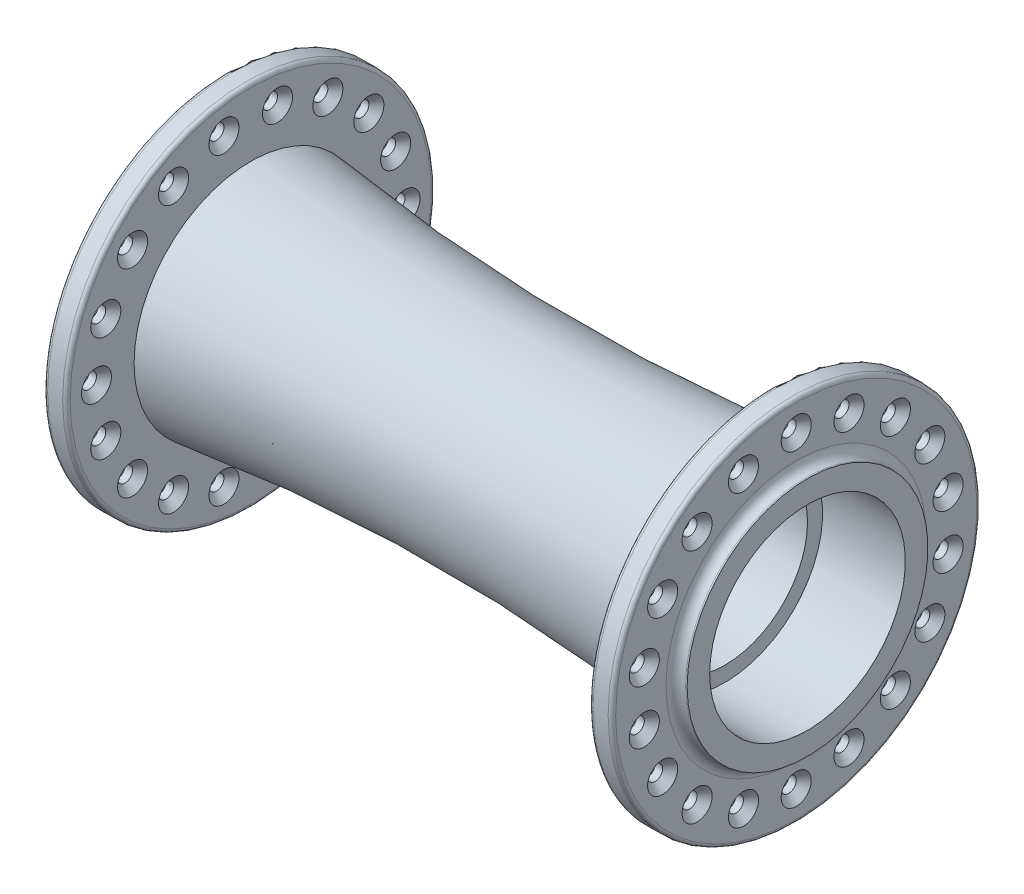
from build123d import *

# Parameters (mm, degrees)
CONG_1_R                                  = 0.5
ESQUISSE2_R                               = 1
ENL_V_MAT_EXTRU_1_DEPTH                   = 3
ESQUISSE3_R                               = 1
ENL_V_MAT_EXTRU_2_DEPTH                   = 3
CHANFREIN1_SIZE                           = 1
R_P_TITION_CIRCULAIRE1_COUNT              = 18
CHANFREIN1_OF_R_P_TITION_CIRCULAIRE1_SIZE = 1
ESQUISSE4_W                               = 11
ESQUISSE4_H                               = 13


with BuildPart() as part:
    # Esquisse1 → Révolution1 (revolve)
    with BuildSketch(Plane.XY, mode=Mode.PRIVATE) as r_volution1_sk:
        with BuildLine():
            Line((-39.25, 11), (39.25, 11))
            Line((39.25, 11), (39.25, 16))
            Line((39.25, 16), (39.05, 16))
            ThreePointArc((39.05, 16), (38.130761184, 16.380761184), (37.75, 17.3))
            Line((37.75, 17.3), (37.75, 24.5))
            Line((37.75, 24.5), (34.75, 24.5))
            Line((34.75, 24.5), (34.75, 15.5))
            ThreePointArc((34.75, 15.5), (0, 13.254435071), (-34.75, 15.5))
            Line((-34.75, 15.5), (-34.75, 24.5))
            Line((-34.75, 24.5), (-37.75, 24.5))
            Line((-37.75, 24.5), (-37.75, 17.3))
            ThreePointArc((-37.75, 17.3), (-38.130761184, 16.380761184), (-39.05, 16))
            Line((-39.05, 16), (-39.25, 16))
            Line((-39.25, 16), (-39.25, 11))
        make_face()
    revolve(r_volution1_sk.sketch.rotate(Axis((-56.164462081, 0, 0), (1, 0, 0)), 90), axis=Axis((-56.164462081, 0, 0), (1, 0, 0)))  # turned: the seam where the file's is

    # Congé1
    cong_1_edges = [part.edges().sort_by_distance(p)[0] for p in [
        (34.75, 0, -24.5),
        (37.75, 0, -24.5),
        (-37.75, 0, -24.5),
        (-34.75, 0, -24.5),
    ]]
    fillet(cong_1_edges, radius=CONG_1_R)

    # Esquisse2 → Enlèv. mat.-Extru.1 (cut)
    with BuildSketch(Plane(origin=(37.75, 0, 0), x_dir=(0, 0, -1), z_dir=(1, 0, 0))):
        with Locations((0, 20.5)):
            Circle(ESQUISSE2_R)
    enl_v_mat_extru_1 = extrude(amount=-ENL_V_MAT_EXTRU_1_DEPTH, mode=Mode.SUBTRACT)

    # Esquisse3 → Enlèv. mat.-Extru.2 (cut)
    with BuildSketch(Plane.ZY.offset(37.75)):
        with Locations((-3.559787642, 20.188558937)):
            Circle(ESQUISSE3_R)
    enl_v_mat_extru_2 = extrude(amount=-ENL_V_MAT_EXTRU_2_DEPTH, mode=Mode.SUBTRACT)

    # Chanfrein1
    chanfrein1_edges = [part.edges().sort_by_distance(p)[0] for p in [
        (37.75, 20.5, 1),
        (34.75, 20.5, 1),
        (-34.75, 20.188558937, -4.559787642),
        (-37.75, 20.188558937, -4.559787642),
    ]]
    chamfer(chanfrein1_edges, length=CHANFREIN1_SIZE)

    # Répétition circulaire1: Enlèv. mat.-Extru.1, Enlèv. mat.-Extru.2 ×18 about axis
    r_p_tition_circulaire1_axis = Axis((0, 0, 0), (1, 0, 0))
    add([enl_v_mat_extru_1.rotate(r_p_tition_circulaire1_axis, i * 360 / R_P_TITION_CIRCULAIRE1_COUNT) for i in range(1, R_P_TITION_CIRCULAIRE1_COUNT)], mode=Mode.SUBTRACT)
    add([enl_v_mat_extru_2.rotate(r_p_tition_circulaire1_axis, i * 360 / R_P_TITION_CIRCULAIRE1_COUNT) for i in range(1, R_P_TITION_CIRCULAIRE1_COUNT)], mode=Mode.SUBTRACT)

    # Chanfrein1 of Répétition circulaire1
    chanfrein1_of_r_p_tition_circulaire1_edges = [part.edges().sort_by_distance(p)[0] for p in [
        (37.75, 18.921678583, 7.951105559),
        (34.75, 18.921678583, 7.951105559),
        (-34.75, 20.53057908, 2.620095021),
        (-37.75, 20.53057908, 2.620095021),
        (37.75, 15.061123474, 13.943190442),
        (34.75, 15.061123474, 13.943190442),
        (-34.75, 18.396308387, 9.483955557),
        (-37.75, 18.396308387, 9.483955557),
        (37.75, 9.383974596, 18.253520778),
        (34.75, 9.383974596, 18.253520778),
        (-34.75, 14.043171402, 15.203911084),
        (-37.75, 14.043171402, 15.203911084),
        (37.75, 2.574979889, 20.362207114),
        (34.75, 2.574979889, 20.362207114),
        (-34.75, 7.996220691, 19.090050548),
        (-37.75, 7.996220691, 19.090050548),
        (37.75, -4.544595395, 20.014910759),
        (34.75, -4.544595395, 20.014910759),
        (-34.75, 0.984807753, 20.673648178),
        (-37.75, 0.984807753, 20.673648178),
        (37.75, -11.116025404, 17.253520778),
        (34.75, -11.116025404, 17.253520778),
        (-34.75, -6.145387534, 19.763698726),
        (-37.75, -6.145387534, 19.763698726),
        (37.75, -16.346698694, 12.411101555),
        (34.75, -16.346698694, 12.411101555),
        (-34.75, -12.534358389, 16.469955527),
        (-37.75, -12.534358389, 16.469955527),
        (37.75, -19.605718869, 6.071720317),
        (34.75, -19.605718869, 6.071720317),
        (-34.75, -17.411500634, 11.189692621),
        (-37.75, -17.411500634, 11.189692621),
        (37.75, -20.5, -1),
        (34.75, -20.5, -1),
        (-34.75, -20.188558937, 4.559787642),
        (-37.75, -20.188558937, 4.559787642),
        (37.75, -18.921678583, -7.951105559),
        (34.75, -18.921678583, -7.951105559),
        (-34.75, -20.53057908, -2.620095021),
        (-37.75, -20.53057908, -2.620095021),
        (37.75, -15.061123474, -13.943190442),
        (34.75, -15.061123474, -13.943190442),
        (-34.75, -18.396308387, -9.483955557),
        (-37.75, -18.396308387, -9.483955557),
        (37.75, -9.383974596, -18.253520778),
        (34.75, -9.383974596, -18.253520778),
        (-34.75, -14.043171402, -15.203911084),
        (-37.75, -14.043171402, -15.203911084),
        (37.75, -2.574979889, -20.362207114),
        (34.75, -2.574979889, -20.362207114),
        (-34.75, -7.996220691, -19.090050548),
        (-37.75, -7.996220691, -19.090050548),
        (37.75, 4.544595395, -20.014910759),
        (34.75, 4.544595395, -20.014910759),
        (-34.75, -0.984807753, -20.673648178),
        (-37.75, -0.984807753, -20.673648178),
        (37.75, 11.116025404, -17.253520778),
        (34.75, 11.116025404, -17.253520778),
        (-34.75, 6.145387534, -19.763698726),
        (-37.75, 6.145387534, -19.763698726),
        (37.75, 16.346698694, -12.411101555),
        (34.75, 16.346698694, -12.411101555),
        (-34.75, 12.534358389, -16.469955527),
        (-37.75, 12.534358389, -16.469955527),
        (37.75, 19.605718869, -6.071720317),
        (34.75, 19.605718869, -6.071720317),
        (-34.75, 17.411500634, -11.189692621),
        (-37.75, 17.411500634, -11.189692621),
    ]]
    chamfer(chanfrein1_of_r_p_tition_circulaire1_edges, length=CHANFREIN1_OF_R_P_TITION_CIRCULAIRE1_SIZE)

    # Esquisse4 → Enlèvement de matière-Révolution3 (revolve, cut)
    with BuildSketch(Plane.XY, mode=Mode.PRIVATE) as enl_vement_de_mati_re_r_volution3_sk:
        with Locations((-33.75, 6.5)):
            Rectangle(ESQUISSE4_W, ESQUISSE4_H)
        with Locations((33.75, 6.5)):
            Rectangle(ESQUISSE4_W, ESQUISSE4_H)
    revolve(enl_vement_de_mati_re_r_volution3_sk.sketch.rotate(Axis((-42.495835783, 0, 0), (1, 0, 0)), 90), axis=Axis((-42.495835783, 0, 0), (1, 0, 0)), mode=Mode.SUBTRACT)  # turned: the seam where the file's is


solid = part.part
